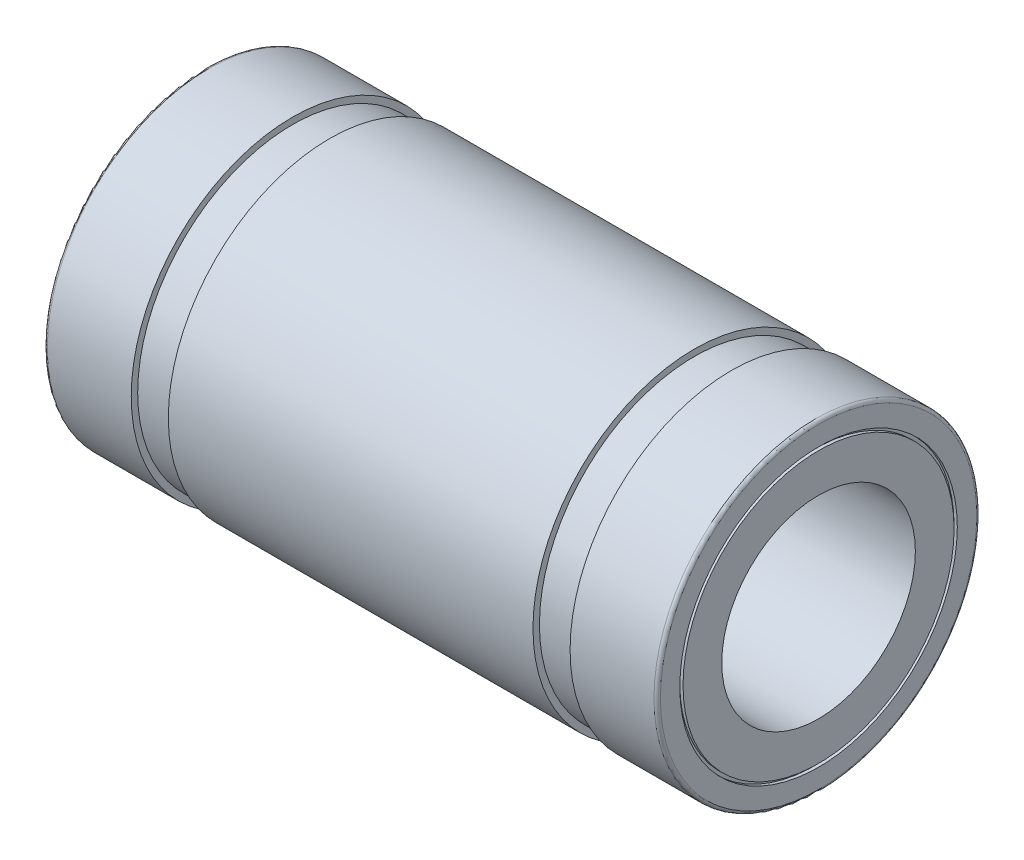
from build123d import *


with BuildPart() as part:
    # Sketch1 → Revolve1 (revolve)
    with BuildSketch(Plane(origin=(0, 0, 0), x_dir=(-1, 0, 0), z_dir=(0, 0, -1))):
        with BuildLine():
            Line((-9.4, 4.2), (-9.5, 4.2))
            Line((-9.5, 4.2), (-9.5, 3))
            Line((-9.5, 3), (9.5, 3))
            Line((9.5, 3), (9.5, 4.2))
            Line((9.5, 4.2), (9.4, 4.2))
            Line((9.4, 4.2), (9.4, 4.3))
            Line((9.4, 4.3), (9.5, 4.3))
            Line((9.5, 4.3), (9.5, 4.9))
            ThreePointArc((9.5, 4.9), (9.470710678, 4.970710678), (9.4, 5))
            Line((9.4, 5), (6.8, 5))
            Line((6.8, 5), (6.8, 4.8))
            Line((6.8, 4.8), (5.65, 4.8))
            Line((5.65, 4.8), (5.65, 5))
            Line((5.65, 5), (-5.65, 5))
            Line((-5.65, 5), (-5.65, 4.8))
            Line((-5.65, 4.8), (-6.8, 4.8))
            Line((-6.8, 4.8), (-6.8, 5))
            Line((-6.8, 5), (-9.4, 5))
            ThreePointArc((-9.4, 5), (-9.470710678, 4.970710678), (-9.5, 4.9))
            Line((-9.5, 4.9), (-9.5, 4.3))
            Line((-9.5, 4.3), (-9.4, 4.3))
            Line((-9.4, 4.3), (-9.4, 4.2))
        make_face()
    revolve(axis=Axis((9.5, 0, 0), (-1, 0, 0)))


solid = part.part
